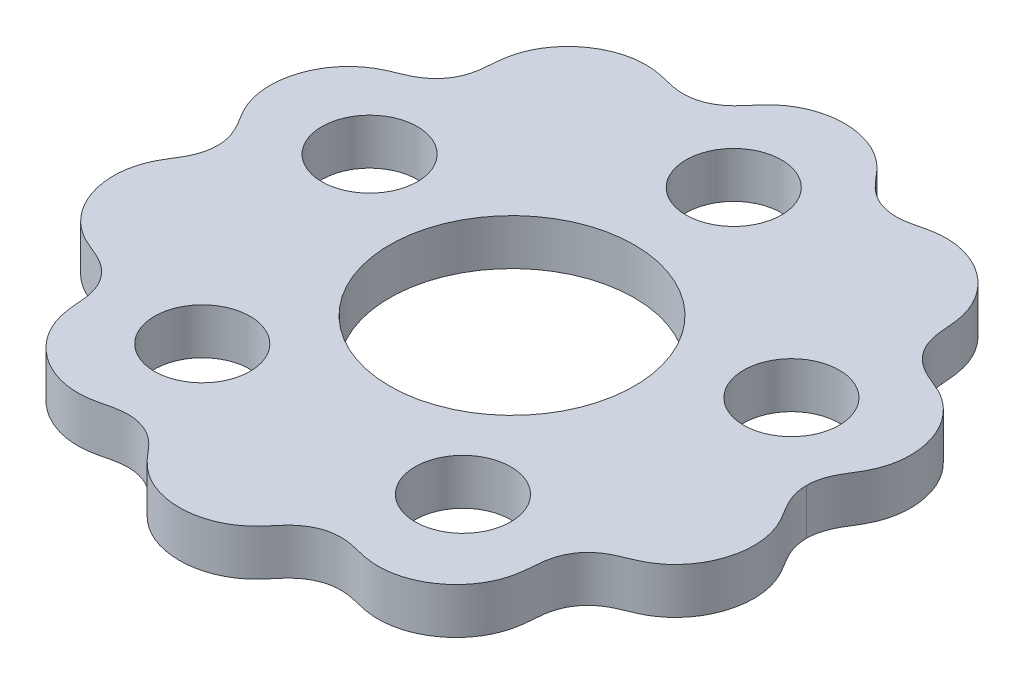
from build123d import *

# Parameters (mm, degrees)
BOSS_EXTRUDE1_DEPTH = 6
SKETCH2_R           = 16
SKETCH2_R_2         = 6.25
CUT_EXTRUDE1_DEPTH  = 19


with BuildPart() as part:
    # Sketch1 → Boss-Extrude1 (new body)
    with BuildSketch(Plane(origin=(0, 0, 0), x_dir=(1, 0, 0), z_dir=(0, 1, 0))):
        with BuildLine():
            add(Edge.make_bspline(
                [(38.5, -2.27e-07), (38.5, -0.043470396), (38.500828162, -0.107545255), (38.503588715, -0.223659382), (38.509794397, -0.35941934), (38.516408597, -0.462758193), (38.526732839, -0.588607669), (38.542364014, -0.739920533), (38.565289341, -0.917951981), (38.597837579, -1.118923787), (38.636592503, -1.318623915), (38.681507762, -1.517051901), (38.73244095, -1.714006008), (38.803489693, -1.958154652), (38.914023171, -2.289417724), (39.077841432, -2.702306671), (39.309257683, -3.189321959), (39.591409701, -3.699386778), (39.992920058, -4.361820486), (40.510801203, -5.177206446), (41.093977751, -6.260268572), (41.619305942, -7.723123096), (41.903253043, -9.32343001), (41.910419516, -11.017397237), (41.635656581, -12.710748898), (41.109930516, -14.304915331), (40.281391526, -15.899355985), (39.295627515, -17.174695403), (38.276113899, -18.132391119), (37.315668596, -18.817660728), (36.564343747, -19.256840177), (35.784095753, -19.629529715), (34.988941495, -19.953634526), (34.183619141, -20.280243466), (33.390310312, -20.662754519), (32.457693416, -21.240465676), (31.507746443, -22.077197191), (30.667603801, -23.228697843), (30.098257489, -24.648516652), (29.84844567, -26.051974778), (29.781056781, -27.347402648), (29.671977263, -28.520230893), (29.429278506, -29.720443213), (28.9920217, -31.029370818), (28.124285706, -32.701751225), (26.840343181, -34.246776755), (25.275779542, -35.491498125), (23.478004783, -36.432709165), (21.913223121, -36.949305046), (20.364518433, -37.182953417), (18.885461733, -37.158808152), (17.643275736, -36.975427587), (16.495260417, -36.686740169), (15.265204015, -36.384539815), (13.916906036, -36.241303965), (12.431912432, -36.384378335), (11.076192178, -36.870890154), (9.971216488, -37.572870605), (9.132234317, -38.335594229), (8.528195507, -39.005410004), (7.981233349, -39.664239916), (7.448305996, -40.276858975), (6.715993714, -41.018042711), (5.667480493, -41.866015956), (4.292046179, -42.651321874), (2.579161314, -43.246381255), (0.793103598, -43.529398082), (-0.93744641, -43.517220067), (-2.695715174, -43.213670595), (-4.373132154, -42.610646718), (-5.719625125, -41.82838078), (-6.747459142, -40.98962338), (-7.477029215, -40.245680746), (-8.011084692, -39.628429622), (-8.557184562, -38.971265503), (-9.158599236, -38.309736697), (-9.991781441, -37.558932749), (-11.086993502, -36.866847551), (-12.435078351, -36.384075198), (-13.916913986, -36.241298882), (-15.265192629, -36.384549203), (-16.495279367, -36.68672092), (-17.643243408, -36.975461318), (-18.885511707, -37.158754303), (-20.101393148, -37.178731745), (-21.282768126, -37.044348464), (-22.518158934, -36.749655236), (-23.71121442, -36.310579085), (-25.275729309, -35.491552369), (-26.840377568, -34.246739557), (-28.124265745, -32.701772854), (-28.992031355, -31.029360487), (-29.429272745, -29.720449617), (-29.671981334, -28.520226691), (-29.781054173, -27.347405753), (-29.848447076, -26.051973458), (-30.098256574, -24.648517914), (-30.66760424, -23.228697355), (-31.50774586, -22.077198013), (-32.457693426, -21.240465301), (-33.390309873, -20.662755323), (-34.183619126, -20.280242211), (-34.988940921, -19.953637036), (-35.784095995, -19.629525805), (-36.564342819, -19.256846455), (-37.315669245, -18.81765327), (-38.27611222, -18.132404625), (-39.29563009, -17.17467154), (-40.281386546, -15.899398131), (-41.268942654, -13.99885539), (-41.843355972, -11.965470402), (-41.961627302, -10.09779934), (-41.758306879, -8.493907757), (-41.483766237, -7.394538802), (-41.182535484, -6.52810293), (-40.805356778, -5.718172081), (-40.372982399, -4.965573584), (-39.970459017, -4.320895807), (-39.628372221, -3.764876777), (-39.343885565, -3.255405419), (-39.119999057, -2.792562413), (-38.949893586, -2.382055007), (-38.824037871, -2.02870762), (-38.717162799, -1.669514946), (-38.630392956, -1.304012939), (-38.572807506, -0.981808573), (-38.536942229, -0.70087716), (-38.516182413, -0.470293124), (-38.505089867, -0.28415174), (-38.500925433, -0.119656785), (-38.500000002, -0.039796198), (-38.5, -5.42e-07)],
                knots=[0.075602386, 0.075602386, 0.075602386, 0.075602386, 0.075602386, 0.076826597, 0.077438702, 0.078050807, 0.078662912, 0.079275017, 0.080499226, 0.081714734, 0.082930242, 0.08414575, 0.085361258, 0.086576765, 0.087792273, 0.090223289, 0.093705502, 0.097187715, 0.100669928, 0.104152141, 0.112217423, 0.120282706, 0.129996681, 0.141147781, 0.150861628, 0.160575475, 0.170839438, 0.181103401, 0.193620959, 0.198877994, 0.20413503, 0.209265814, 0.214396599, 0.219527384, 0.224658169, 0.230039144, 0.235420119, 0.245691489, 0.254714145, 0.26373004, 0.271662559, 0.279595079, 0.2857256, 0.29185612, 0.300873205, 0.312487809, 0.330521672, 0.339405962, 0.348290253, 0.36082853, 0.369712438, 0.376625643, 0.383538849, 0.390770364, 0.39800188, 0.406889931, 0.41578052, 0.426123779, 0.432044442, 0.437965106, 0.442815543, 0.44766598, 0.452516417, 0.457366854, 0.467699893, 0.479800139, 0.490133997, 0.500467856, 0.510726651, 0.520985446, 0.532590331, 0.542847928, 0.547723897, 0.552599866, 0.557475834, 0.562351803, 0.568151797, 0.573951791, 0.58421947, 0.593110059, 0.60199811, 0.609229626, 0.616461141, 0.623374346, 0.630287552, 0.63917146, 0.645440598, 0.651709737, 0.660594028, 0.669478319, 0.687512181, 0.699126785, 0.708143869, 0.71427439, 0.720404911, 0.72833743, 0.736269949, 0.745285844, 0.7543085, 0.764579871, 0.769960845, 0.77534182, 0.780472605, 0.78560339, 0.790734175, 0.79586496, 0.801121996, 0.806379031, 0.818896589, 0.829160552, 0.839424515, 0.857344209, 0.868977832, 0.873457429, 0.877937025, 0.884403667, 0.890870308, 0.894771061, 0.898671815, 0.902572569, 0.906473323, 0.90871294, 0.910952556, 0.913192173, 0.91543179, 0.917673246, 0.919914701, 0.921035429, 0.922156157, 0.923276885, 0.924397616, 0.924397616, 0.924397616, 0.924397616, 0.924397616], degree=4))
            add(Edge.make_bspline(
                [(38.5, -2.27e-07), (38.5, 0.04347017), (38.500828162, 0.107545028), (38.503588714, 0.223659155), (38.509794396, 0.359419113), (38.516408595, 0.462757967), (38.526732836, 0.588607442), (38.542364011, 0.739920306), (38.565289338, 0.917951754), (38.597837575, 1.118923561), (38.636592497, 1.318623688), (38.681507756, 1.517051675), (38.732440943, 1.714005782), (38.803489685, 1.958154426), (38.914023162, 2.289417499), (39.077841421, 2.702306447), (39.30925767, 3.189321735), (39.591409685, 3.699386556), (39.99292004, 4.361820265), (40.510801182, 5.177206227), (41.093977726, 6.260268356), (41.61930591, 7.723122882), (41.903253005, 9.323429797), (41.91041947, 11.017397024), (41.635656529, 12.710748684), (41.109930458, 14.304915115), (40.28139146, 15.899355766), (39.295627445, 17.17469518), (38.276113825, 18.132390892), (37.315668519, 18.817660497), (36.564343668, 19.256839942), (35.784095673, 19.629529477), (34.988941413, 19.953634285), (34.183619058, 20.280243221), (33.390310227, 20.662754271), (32.457693329, 21.240465424), (31.507746353, 22.077196936), (30.667603706, 23.228697584), (30.098257388, 24.648516391), (29.848445564, 26.051974516), (29.781056669, 27.347402385), (29.671977147, 28.52023063), (29.429278385, 29.72044295), (28.992021573, 31.029370553), (28.124285572, 32.701750955), (26.840343041, 34.24677648), (25.275779397, 35.491497844), (23.478004634, 36.432708877), (21.91322297, 36.949304751), (20.364518281, 37.182953116), (18.88546158, 37.158807845), (17.643275585, 36.975427275), (16.495260267, 36.686739852), (15.265203866, 36.384539493), (13.916905887, 36.241303638), (12.431912283, 36.384378001), (11.076192027, 36.870889815), (9.971216334, 37.572870262), (9.13223416, 38.335593883), (8.528195348, 39.005409655), (7.981233187, 39.664239564), (7.448305832, 40.276858621), (6.715993546, 41.018042354), (5.667480321, 41.866015595), (4.292046005, 42.651321507), (2.579161137, 43.246380881), (0.79310342, 43.529397701), (-0.937446588, 43.517219679), (-2.695715351, 43.213670199), (-4.373132329, 42.610646315), (-5.719625296, 41.828380372), (-6.74745931, 40.989622968), (-7.47702938, 40.245680331), (-8.011084854, 39.628429205), (-8.557184721, 38.971265084), (-9.158599393, 38.309736275), (-9.991781594, 37.558932324), (-11.086993653, 36.866847121), (-12.4350785, 36.384074763), (-13.916914134, 36.241298441), (-15.265192778, 36.384548756), (-16.495279517, 36.686720468), (-17.643243559, 36.975460861), (-18.885511859, 37.158753842), (-20.1013933, 37.178731278), (-21.282768278, 37.044347992), (-22.518159084, 36.749654759), (-23.711214569, 36.310578603), (-25.275729454, 35.491551881), (-26.840377708, 34.246739063), (-28.124265879, 32.701772355), (-28.992031482, 31.029359984), (-29.429272867, 29.720449112), (-29.671981451, 28.520226185), (-29.781054285, 27.347405247), (-29.848447182, 26.051972951), (-30.098256675, 24.648517406), (-30.667604335, 23.228696845), (-31.50774595, 22.0771975), (-32.457693513, 21.240464784), (-33.390309958, 20.662754802), (-34.183619209, 20.280241687), (-34.988941003, 19.953636509), (-35.784096075, 19.629525274), (-36.564342898, 19.256845921), (-37.315669322, 18.817652733), (-38.276112294, 18.132404084), (-39.295630161, 17.174670995), (-40.281386611, 15.899397582), (-41.268942712, 13.998854836), (-41.843356021, 11.965469846), (-41.961627344, 10.097798783), (-41.758306914, 8.493907202), (-41.483766267, 7.394538248), (-41.182535511, 6.528102377), (-40.805356801, 5.71817153), (-40.372982419, 4.965573034), (-39.970459035, 4.320895259), (-39.628372236, 3.764876231), (-39.343885579, 3.255404873), (-39.119999069, 2.792561868), (-38.949893596, 2.382054464), (-38.824037879, 2.028707077), (-38.717162806, 1.669514403), (-38.630392961, 1.304012396), (-38.57280751, 0.981808031), (-38.536942232, 0.700876618), (-38.516182415, 0.470292582), (-38.505089868, 0.284151198), (-38.500925433, 0.119656243), (-38.500000002, 0.039795656), (-38.5, -5.42e-07)],
                knots=[0.075602388, 0.075602388, 0.075602388, 0.075602388, 0.075602388, 0.076826597, 0.077438702, 0.078050807, 0.078662912, 0.079275017, 0.080499226, 0.081714734, 0.082930242, 0.08414575, 0.085361258, 0.086576765, 0.087792273, 0.090223289, 0.093705502, 0.097187715, 0.100669928, 0.104152141, 0.112217423, 0.120282706, 0.129996681, 0.141147781, 0.150861628, 0.160575475, 0.170839438, 0.181103401, 0.193620959, 0.198877994, 0.20413503, 0.209265814, 0.214396599, 0.219527384, 0.224658169, 0.230039144, 0.235420119, 0.245691489, 0.254714145, 0.26373004, 0.271662559, 0.279595079, 0.2857256, 0.29185612, 0.300873205, 0.312487809, 0.330521672, 0.339405962, 0.348290253, 0.36082853, 0.369712438, 0.376625643, 0.383538849, 0.390770364, 0.39800188, 0.406889931, 0.41578052, 0.426123779, 0.432044442, 0.437965106, 0.442815543, 0.44766598, 0.452516417, 0.457366854, 0.467699893, 0.479800139, 0.490133997, 0.500467856, 0.510726651, 0.520985446, 0.532590331, 0.542847928, 0.547723897, 0.552599866, 0.557475834, 0.562351803, 0.568151797, 0.573951791, 0.58421947, 0.593110059, 0.60199811, 0.609229626, 0.616461141, 0.623374346, 0.630287552, 0.63917146, 0.645440598, 0.651709737, 0.660594028, 0.669478319, 0.687512181, 0.699126785, 0.708143869, 0.71427439, 0.720404911, 0.72833743, 0.736269949, 0.745285844, 0.7543085, 0.764579871, 0.769960845, 0.77534182, 0.780472605, 0.78560339, 0.790734175, 0.79586496, 0.801121996, 0.806379031, 0.818896589, 0.829160552, 0.839424515, 0.857344209, 0.868977832, 0.873457429, 0.877937025, 0.884403667, 0.890870308, 0.894771061, 0.898671815, 0.902572569, 0.906473323, 0.90871294, 0.910952556, 0.913192173, 0.91543179, 0.917673246, 0.919914701, 0.921035429, 0.922156157, 0.923276885, 0.924397612, 0.924397612, 0.924397612, 0.924397612, 0.924397612], degree=4))
        make_face()
    extrude(amount=BOSS_EXTRUDE1_DEPTH)

    # Sketch2 → Cut-Extrude1 (cut)
    with BuildSketch(Plane(origin=(0, 6, 0), x_dir=(1, 0, 0), z_dir=(0, 1, 0))):
        with Locations(Location((0, 0, 0), (0, 0, 270))):
            Circle(SKETCH2_R)
        with Locations(Location((27.580115252, 8.963104522, 0), (0, 0, 270))):
            Circle(SKETCH2_R_2)
        with Locations(Location((17.047143282, -23.460496711, 0), (0, 0, 270))):
            Circle(SKETCH2_R_2)
        with Locations(Location((-17.044401293, -23.462488883, 0), (0, 0, 270))):
            Circle(SKETCH2_R_2)
        with Locations(Location((-27.581162599, 8.959881121, 0), (0, 0, 270))):
            Circle(SKETCH2_R_2)
        with Locations(Location((-0.001694642, 28.99999995, 0), (0, 0, 270))):
            Circle(SKETCH2_R_2)
    extrude(amount=-CUT_EXTRUDE1_DEPTH, mode=Mode.SUBTRACT)


solid = part.part
